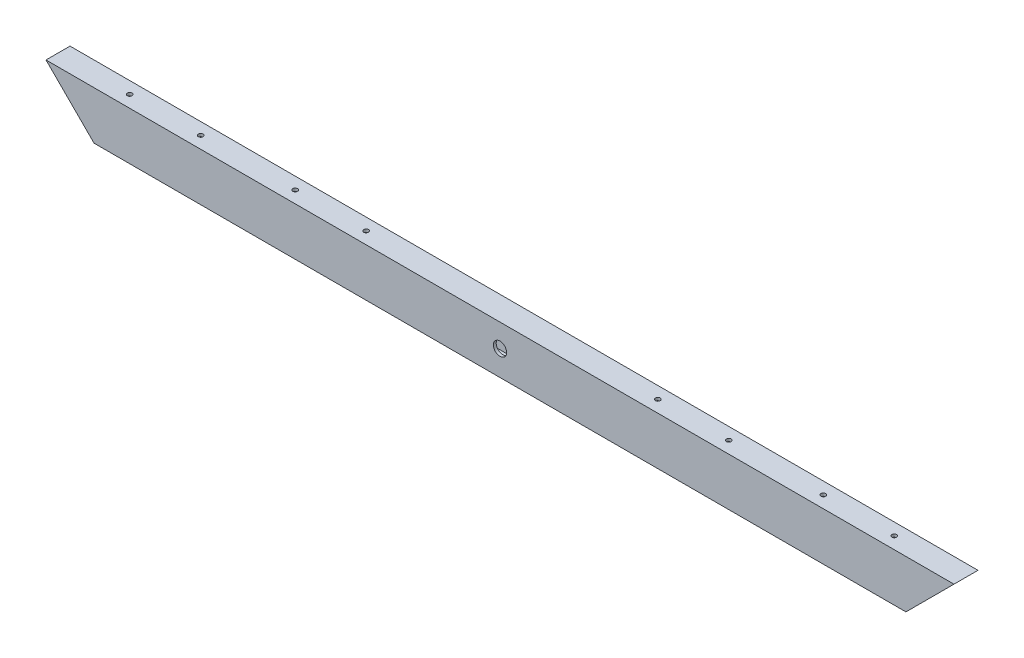
from build123d import *

# Parameters (mm, degrees)
SKETCH1_R               = 7
BOSS_EXTRUDE1_DEPTH     = 25.4
CUT_EXTRUDE1_DEPTH      = 1046.4
CUT_EXTRUDE1_DEPTH_BACK = 201.4
SKETCH3_W               = 19.4
SKETCH3_H               = 44.8
CUT_EXTRUDE2_DEPTH      = 22
CUT_EXTRUDE2_DEPTH_BACK = 22
SKETCH4_R               = 2.5


with BuildPart() as part:
    # Sketch1 → Boss-Extrude1 (new body)
    with BuildSketch(Plane.XY):
        Polygon((-50.8, 50.8), (0, 0), (858.4, 0), (909.2, 50.8), align=None)
        with Locations((429.2, 26.4)):
            Circle(SKETCH1_R, mode=Mode.SUBTRACT)
    extrude(amount=BOSS_EXTRUDE1_DEPTH)

    # Sketch3 → Cut-Extrude1 (cut, two sides: drawn at the far end of the back side and taken through both)
    with BuildSketch(Plane(origin=(0, 0, 0), x_dir=(0, 0, -1), z_dir=(1, 0, 0)).offset(-CUT_EXTRUDE1_DEPTH_BACK)):
        with Locations((-12.7, 25.4)):
            Rectangle(SKETCH3_W, SKETCH3_H)
    extrude(amount=CUT_EXTRUDE1_DEPTH + CUT_EXTRUDE1_DEPTH_BACK, mode=Mode.SUBTRACT)

    # Sketch4 → Cut-Extrude2 (cut, two sides: drawn at the far end of the back side and taken through both)
    with BuildSketch(Plane(origin=(0, 50.8, 0), x_dir=(1, 0, 0), z_dir=(0, 1, 0)).offset(-CUT_EXTRUDE2_DEPTH_BACK)):
        with Locations((25, -12.7)):
            Circle(SKETCH4_R)
        with Locations((100, -12.7)):
            Circle(SKETCH4_R)
        with Locations((200, -12.7)):
            Circle(SKETCH4_R)
        with Locations((275, -12.7)):
            Circle(SKETCH4_R)
        with Locations((833.4, -12.7)):
            Circle(SKETCH4_R)
        with Locations((758.4, -12.7)):
            Circle(SKETCH4_R)
        with Locations((658.4, -12.7)):
            Circle(SKETCH4_R)
        with Locations((583.4, -12.7)):
            Circle(SKETCH4_R)
    extrude(amount=CUT_EXTRUDE2_DEPTH + CUT_EXTRUDE2_DEPTH_BACK, mode=Mode.SUBTRACT)


solid = part.part
